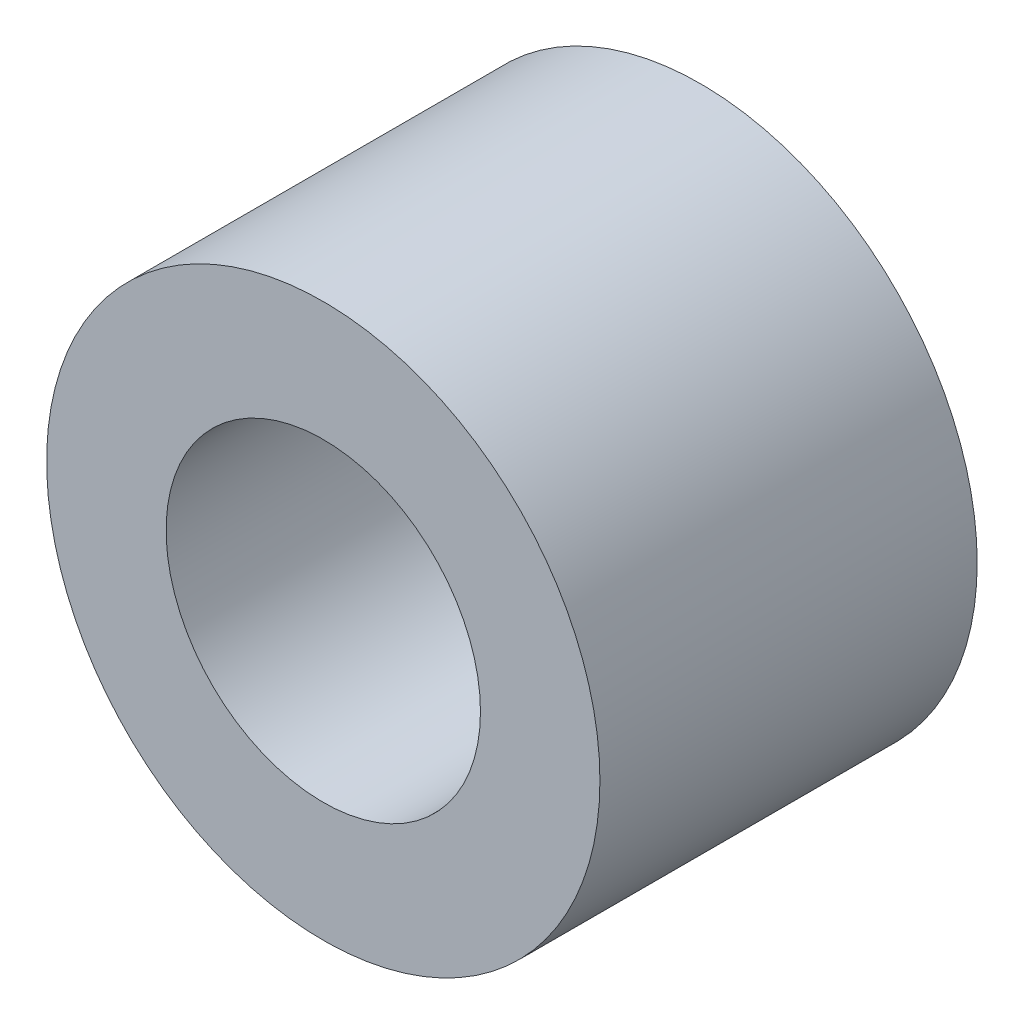
from build123d import *

# Parameters (mm, degrees)
SKETCH_1_R      = 2.2
SKETCH_1_R_2    = 1.25
EXTRUDE_2_DEPTH = 3


with BuildPart() as part:
    # 草图1 → 凸台-拉伸2 (new body)
    with BuildSketch(Plane.XY):
        Circle(SKETCH_1_R)
        Circle(SKETCH_1_R_2, mode=Mode.SUBTRACT)
    extrude(amount=EXTRUDE_2_DEPTH)


solid = part.part
